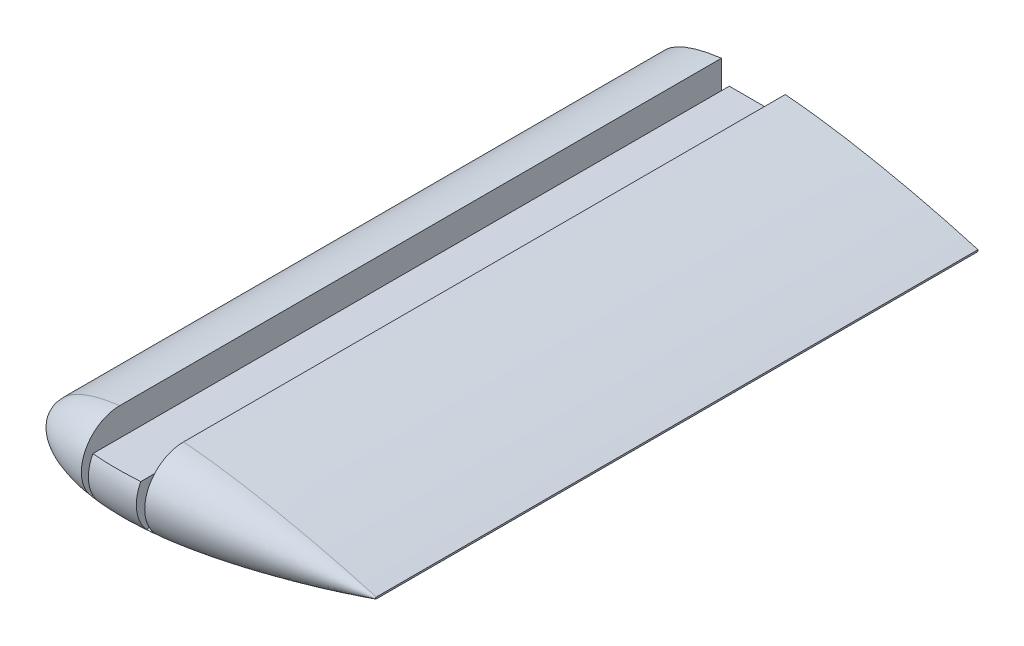
from build123d import *

# Parameters (mm, degrees)
BOSS_EXTRUDE1_DEPTH = 150
REVOLVE1_ANGLE      = 180
CUT_EXTRUDE1_REACH  = 162


with BuildPart() as part:
    # Sketch2 → Boss-Extrude1 (new body)
    with BuildSketch(Plane.XY):
        with BuildLine():
            Line((55.998991919, 0.209938863), (55.998991919, -0.209938863))
            add(Edge.make_bspline(
                [(55.998991919, 0.209938863), (53.463896497, 0.950455214), (48.803904258, 2.233873897), (42.428923908, 3.819934884), (36.743376831, 5.120873453), (31.199749362, 6.287249396), (25.282426203, 7.407488419), (20.176484373, 8.245231015), (14.979623954, 8.974887306), (10.821499069, 9.44862332), (6.697350987, 9.777022894), (3.680655604, 9.939622605), (0.739619613, 10.012665726), (-2.107751213, 9.990028944), (-4.843941705, 9.866960982), (-7.452188048, 9.640899897), (-9.916478705, 9.310630744), (-12.221751766, 8.877222993), (-14.354021752, 8.343659433), (-16.300401345, 7.714341159), (-18.049355518, 6.995399514), (-19.590605164, 6.19339349), (-20.915410238, 5.315562027), (-22.015853697, 4.368064829), (-22.884921184, 3.356491652), (-23.514451457, 2.28497611), (-23.895372624, 1.158788991), (-24.018679664, 0), (-23.895372624, -1.158788991), (-23.514451457, -2.28497611), (-22.884921184, -3.356491652), (-22.015853697, -4.368064829), (-20.915410238, -5.315562027), (-19.590605164, -6.19339349), (-18.049355518, -6.995399514), (-16.300401345, -7.714341159), (-14.354021752, -8.343659433), (-12.221751766, -8.877222993), (-9.916478705, -9.310630744), (-7.452188048, -9.640899897), (-4.843941705, -9.866960982), (-2.107751213, -9.990028944), (0.739619613, -10.012665726), (3.680655604, -9.939622605), (7.74070187, -9.72078634), (12.912832982, -9.241334238), (19.136671313, -8.415754469), (25.28242537, -7.407448977), (31.199752667, -6.287252304), (37.517160947, -4.95809922), (44.742570872, -3.275857272), (51.057566095, -1.626260629), (54.945025722, -0.517808616), (55.95791152, -0.221938691), (55.998991919, -0.209938863)],
                knots=[0, 0, 0, 0, 0.046554703, 0.085193372, 0.115793222, 0.149362634, 0.18504799, 0.221946042, 0.240561295, 0.277549679, 0.295701185, 0.31348255, 0.330796889, 0.347551895, 0.363665842, 0.379065349, 0.393686065, 0.407475418, 0.420391934, 0.432405657, 0.443502806, 0.453686421, 0.462984388, 0.471455944, 0.479204465, 0.486388269, 0.493228974, 0.5, 0.506771026, 0.513611731, 0.520795535, 0.528544056, 0.537015612, 0.546313579, 0.556497194, 0.567594343, 0.579608066, 0.592524582, 0.606313935, 0.620934651, 0.636334158, 0.652448105, 0.669203111, 0.68651745, 0.704298815, 0.740866341, 0.778053958, 0.81495201, 0.850637366, 0.884206778, 0.928744289, 0.981399281, 0.999245596, 1, 1, 1, 1], degree=3))
        make_face()
    extrude(amount=BOSS_EXTRUDE1_DEPTH)

    # Sketch4 → Revolve1 (revolve)
    with BuildSketch(Plane.XY.offset(150)):
        with BuildLine():
            Line((55.998991919, 0), (-23.977717827, 0))
            add(Edge.make_bspline(
                [(55.998991919, 0.209938863), (53.463896497, 0.950455214), (48.803904258, 2.233873897), (42.428923908, 3.819934884), (36.743376831, 5.120873453), (31.199749362, 6.287249396), (25.282426203, 7.407488419), (20.176484373, 8.245231015), (14.979623954, 8.974887306), (10.821499069, 9.44862332), (6.697350987, 9.777022894), (3.680655604, 9.939622605), (0.739619613, 10.012665726), (-2.107751213, 9.990028944), (-4.843941705, 9.866960982), (-7.452188048, 9.640899897), (-9.916478705, 9.310630744), (-12.221751766, 8.877222993), (-14.354021752, 8.343659433), (-16.300401345, 7.714341159), (-18.049355518, 6.995399514), (-19.590605164, 6.19339349), (-20.915410238, 5.315562027), (-22.015853697, 4.368064829), (-22.884921184, 3.356491652), (-23.514451457, 2.28497611), (-23.895372624, 1.158788991), (-23.977717827, 0.384942543), (-23.977717827, 0)],
                knots=[0, 0, 0, 0, 0.046554703, 0.085193372, 0.115793222, 0.149362634, 0.18504799, 0.221946042, 0.240561295, 0.277549679, 0.295701185, 0.31348255, 0.330796889, 0.347551895, 0.363665842, 0.379065349, 0.393686065, 0.407475418, 0.420391934, 0.432405657, 0.443502806, 0.453686421, 0.462984388, 0.471455944, 0.479204465, 0.486388269, 0.493228974, 0.5, 0.5, 0.5, 0.5], degree=3))
            Line((55.998991919, 0.209938863), (55.998991919, 0))
        make_face()
    revolve(axis=Axis((55.998991919, 0, 150), (1, 0, 0)), revolution_arc=REVOLVE1_ANGLE)

    # Sketch3 → Cut-Extrude1 (cut, up to next)
    with BuildSketch(Plane(origin=(0, 0, 0), x_dir=(-1, 0, 0), z_dir=(0, 0, -1)), mode=Mode.PRIVATE) as cut_extrude1_sk1:
        with BuildLine():
            Line((6, -6.5), (7.95, -6.5))
            Line((7.95, -6.5), (7.95, 9.56370057))
            add(Edge.make_bspline(
                [(-7.95, 9.673763928), (-7.525333967, 9.706496284), (-6.094337758, 9.809525273), (-3.680655604, 9.939622605), (-0.739619613, 10.012665726), (2.107751213, 9.990028944), (4.843941705, 9.866960982), (6.778071836, 9.69932668), (7.798061571, 9.581867182), (7.95, 9.56370057)],
                knots=[0.28819337, 0.28819337, 0.28819337, 0.28819337, 0.295701185, 0.31348255, 0.330796889, 0.347551895, 0.363665842, 0.379065349, 0.381762425, 0.381762425, 0.381762425, 0.381762425], degree=3))
            Line((-7.95, 9.673763928), (-7.95, -6.5))
            Line((-7.95, -6.5), (-6, -6.5))
            Line((-6, -6.5), (-6, 4.5))
            Line((-6, 4.5), (6, 4.5))
            Line((6, 4.5), (6, -6.5))
        make_face()
    cut_extrude1_tool1 = extrude(cut_extrude1_sk1.sketch, amount=-CUT_EXTRUDE1_REACH, mode=Mode.PRIVATE) & part.part
    add(cut_extrude1_tool1.solids().sort_by_distance((-6.975, -6.270858, 0))[0], mode=Mode.SUBTRACT)


solid = part.part
